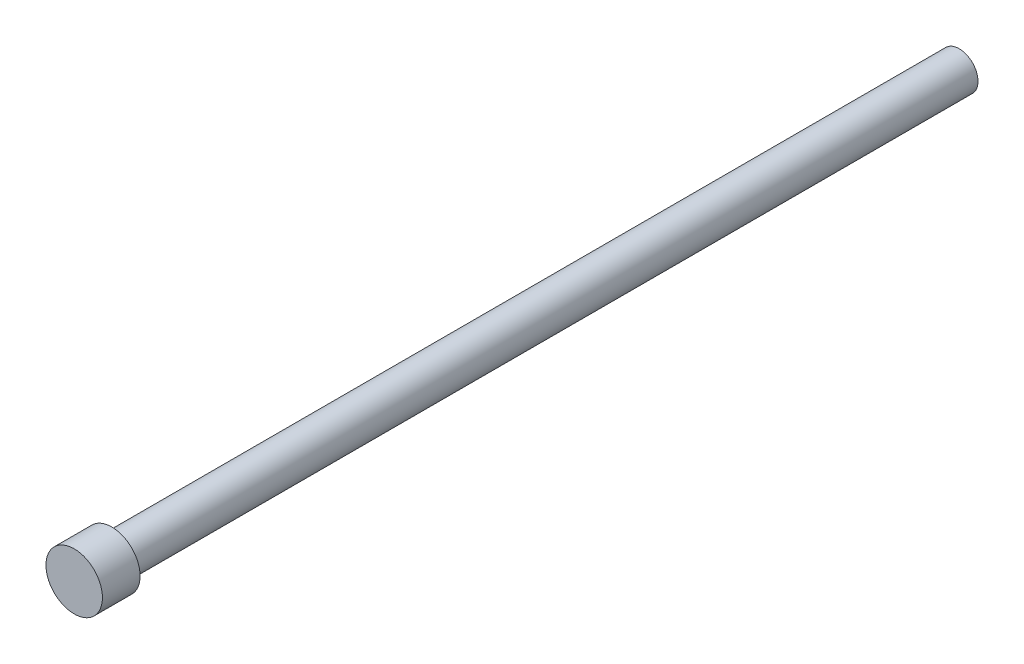
from build123d import *

# Parameters (mm, degrees)
SKETCH_1_R          = 1
EXTRUDE_1_DEPTH     = 45
SKETCH_2_R          = 1.5
EXTRUDE_2_DEPTH     = 2
SKETCH_3_R          = 0.75
CUT_EXTRUDE_1_DEPTH = 20


with BuildPart() as part:
    # 草圖1 → 填料-伸長1 (new body)
    with BuildSketch(Plane.XY):
        Circle(SKETCH_1_R)
    extrude(amount=EXTRUDE_1_DEPTH)

    # 草圖2 → 填料-伸長2 (add)
    with BuildSketch(Plane.XY.offset(45)):
        Circle(SKETCH_2_R)
    extrude(amount=EXTRUDE_2_DEPTH)

    # 草圖3 → 除料-伸長1 (cut)
    with BuildSketch(Plane(origin=(0, 0, 0), x_dir=(-1, 0, 0), z_dir=(0, 0, -1))):
        Circle(SKETCH_3_R)
    extrude(amount=-CUT_EXTRUDE_1_DEPTH, mode=Mode.SUBTRACT)


solid = part.part
